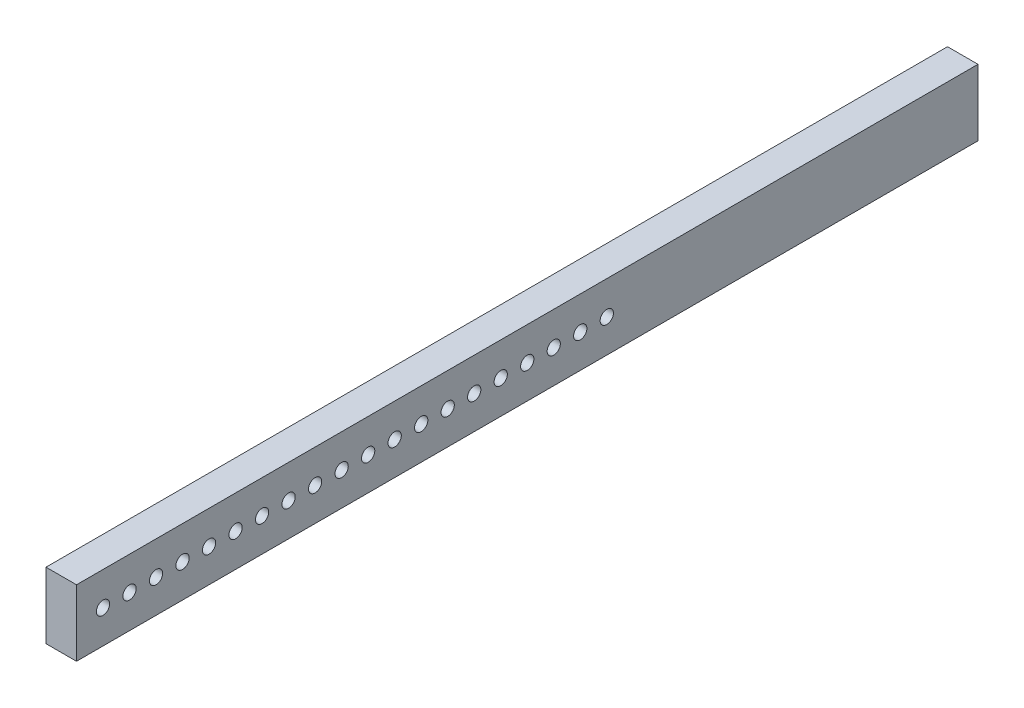
from build123d import *

# Parameters (mm, degrees)
SKETCH1_W           = 680
SKETCH1_H           = 50
SKETCH1_R           = 5
BOSS_EXTRUDE1_DEPTH = 23


with BuildPart() as part:
    # Sketch1 → Boss-Extrude1 (new body)
    with BuildSketch(Plane(origin=(0, 0, 0), x_dir=(0, 0, -1), z_dir=(1, 0, 0))):
        Rectangle(SKETCH1_W, SKETCH1_H)
        with Locations((-320, 0)):
            Circle(SKETCH1_R, mode=Mode.SUBTRACT)
        with Locations((-300, 0)):
            Circle(SKETCH1_R, mode=Mode.SUBTRACT)
        with Locations((-280, 0)):
            Circle(SKETCH1_R, mode=Mode.SUBTRACT)
        with Locations((-260, 0)):
            Circle(SKETCH1_R, mode=Mode.SUBTRACT)
        with Locations((-240, 0)):
            Circle(SKETCH1_R, mode=Mode.SUBTRACT)
        with Locations((-220, 0)):
            Circle(SKETCH1_R, mode=Mode.SUBTRACT)
        with Locations((-200, 0)):
            Circle(SKETCH1_R, mode=Mode.SUBTRACT)
        with Locations((-180, 0)):
            Circle(SKETCH1_R, mode=Mode.SUBTRACT)
        with Locations((-160, 0)):
            Circle(SKETCH1_R, mode=Mode.SUBTRACT)
        with Locations((-140, 0)):
            Circle(SKETCH1_R, mode=Mode.SUBTRACT)
        with Locations((-120, 0)):
            Circle(SKETCH1_R, mode=Mode.SUBTRACT)
        with Locations((-100, 0)):
            Circle(SKETCH1_R, mode=Mode.SUBTRACT)
        with Locations((-80, 0)):
            Circle(SKETCH1_R, mode=Mode.SUBTRACT)
        with Locations((-60, 0)):
            Circle(SKETCH1_R, mode=Mode.SUBTRACT)
        with Locations((-40, 0)):
            Circle(SKETCH1_R, mode=Mode.SUBTRACT)
        with Locations((-20, 0)):
            Circle(SKETCH1_R, mode=Mode.SUBTRACT)
        Circle(SKETCH1_R, mode=Mode.SUBTRACT)
        with Locations((20, 0)):
            Circle(SKETCH1_R, mode=Mode.SUBTRACT)
        with Locations((40, 0)):
            Circle(SKETCH1_R, mode=Mode.SUBTRACT)
        with Locations((60, 0)):
            Circle(SKETCH1_R, mode=Mode.SUBTRACT)
    extrude(amount=BOSS_EXTRUDE1_DEPTH)


solid = part.part
